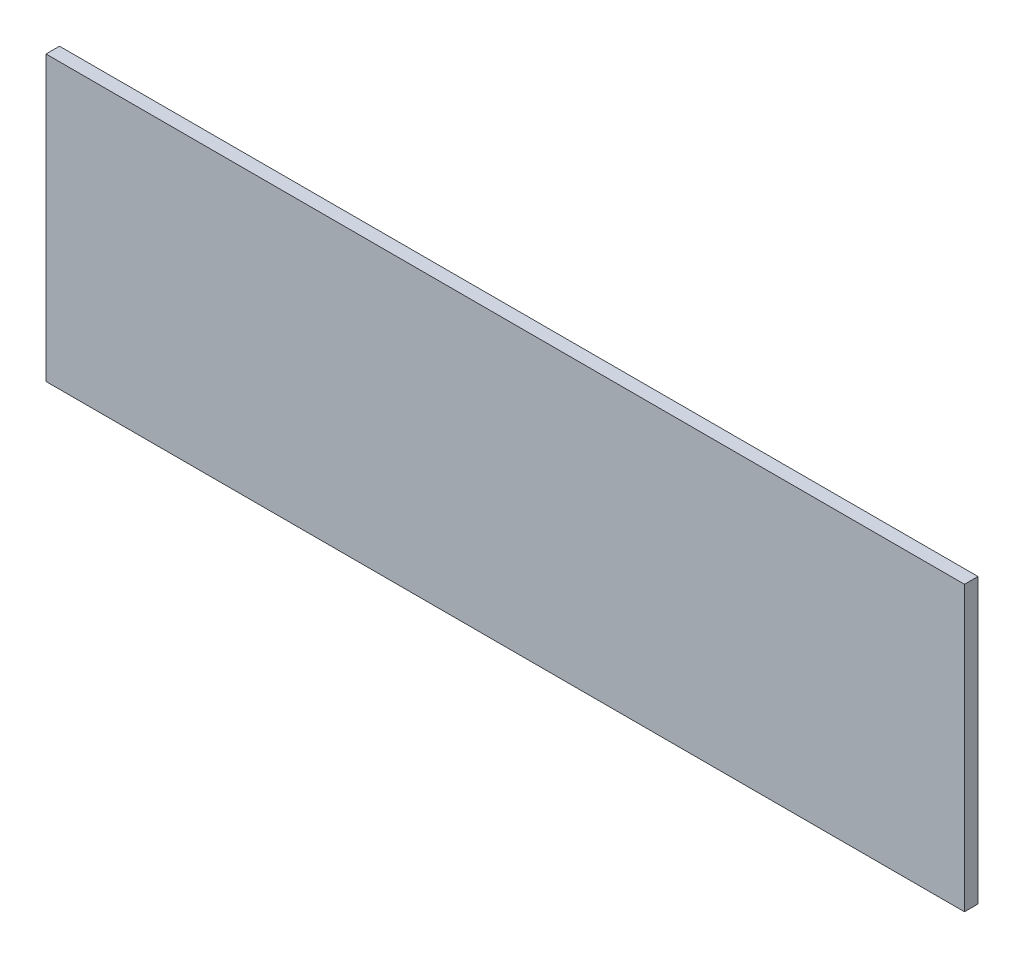
from build123d import *

# Parameters (mm, degrees)
ESQUISSE1_W        = 680
ESQUISSE1_H        = 210
BOSS_EXTRU_1_DEPTH = 10


with BuildPart() as part:
    # Esquisse1 → Boss.-Extru.1 (new body)
    with BuildSketch(Plane.XY):
        Rectangle(ESQUISSE1_W, ESQUISSE1_H)
    extrude(amount=BOSS_EXTRU_1_DEPTH)


solid = part.part
